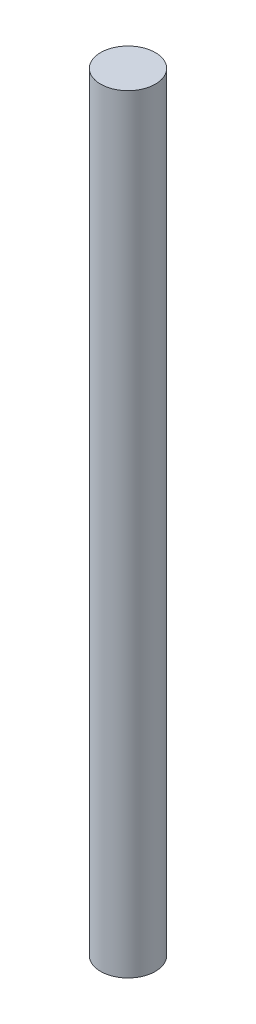
from build123d import *

# Parameters (mm, degrees)
SKETCH1_R                = 2.5
BOSS_EXTRUDE1_DEPTH      = 20.2
BOSS_EXTRUDE1_DEPTH_BACK = 50


with BuildPart() as part:
    # Sketch1 → Boss-Extrude1 (new body, two sides)
    with BuildSketch(Plane(origin=(0, 0, 0), x_dir=(1, 0, 0), z_dir=(0, 1, 0))) as boss_extrude1_sk:
        Circle(SKETCH1_R)
    extrude(amount=BOSS_EXTRUDE1_DEPTH)
    extrude(boss_extrude1_sk.sketch, amount=-BOSS_EXTRUDE1_DEPTH_BACK)


solid = part.part
